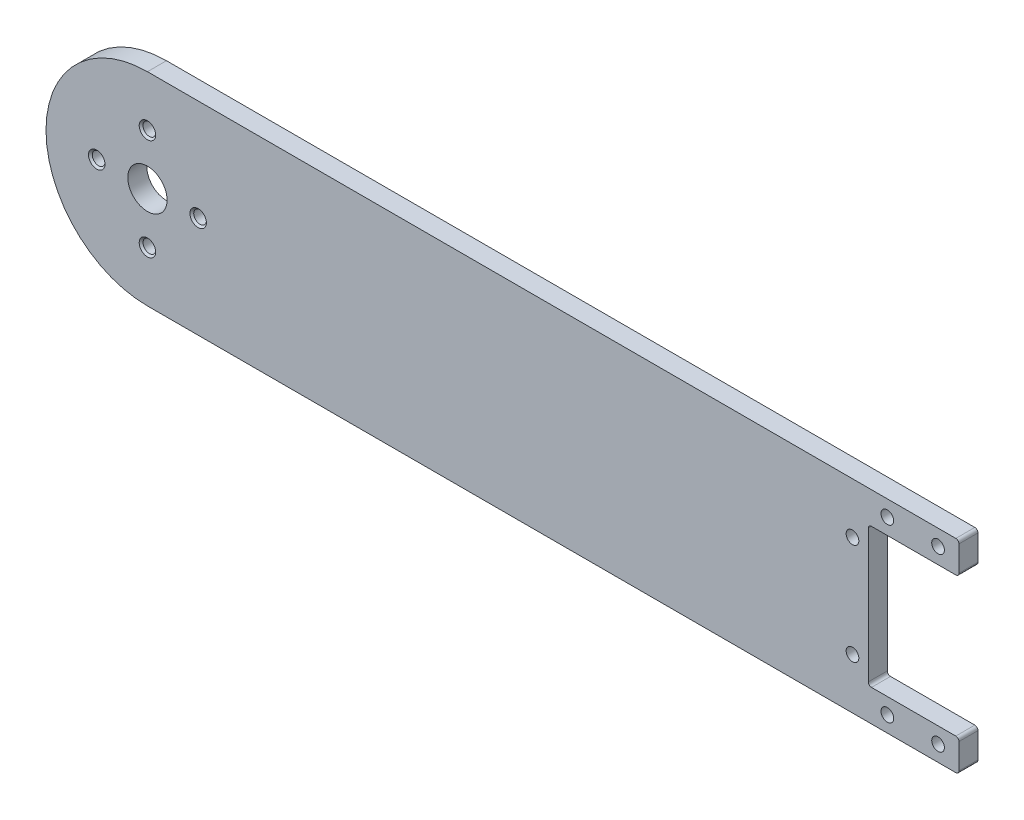
from build123d import *

# Parameters (mm, degrees)
Y_KSEKLIK_EKSTR_ZYON1_DEPTH                    = 3
IZIM2_R                                        = 3.1
KES_EKSTR_ZYON1_DEPTH                          = 4
M2_D_Z_BA_L_MAKINE_VIDAS_IN_HAV_A1_D           = 2
M2_D_Z_BA_L_MAKINE_VIDAS_IN_HAV_A1_CSINK_D     = 2.6
M2_D_Z_BA_L_MAKINE_VIDAS_IN_HAV_A1_CSINK_ANGLE = 90
IZIM26_W                                       = 22.3
IZIM26_H                                       = 22
KES_EKSTR_ZYON4_DEPTH                          = 4
M2_D_Z_BA_L_MAKINE_VIDAS_IN_HAV_A2_D           = 2
M2_D_Z_BA_L_MAKINE_VIDAS_IN_HAV_A2_CSINK_D     = 2.6
M2_D_Z_BA_L_MAKINE_VIDAS_IN_HAV_A2_CSINK_ANGLE = 90
IZIM33_W                                       = 8
IZIM33_H                                       = 32
KES_EKSTR_ZYON5_DEPTH                          = 10
RADYUS1_R                                      = 0.5


with BuildPart() as part:
    # Çizim1 → Yükseklik-Ekstrüzyon1 (new body)
    with BuildSketch(Plane.XY):
        with BuildLine():
            ThreePointArc((-61, 16), (-77, 0), (-61, -16))
            Line((-61, -16), (75, -16))
            Line((75, -16), (75, 16))
            Line((75, 16), (-61, 16))
        make_face()
    extrude(amount=Y_KSEKLIK_EKSTR_ZYON1_DEPTH)

    # Çizim2 → Kes-Ekstrüzyon1 (cut, through all)
    with BuildSketch(Plane.XY.offset(3)):
        with Locations((-61, 0)):
            Circle(IZIM2_R)
    extrude(amount=-KES_EKSTR_ZYON1_DEPTH, mode=Mode.SUBTRACT)

    # M2 Düz Başlı Makine Vidası İçin Havşa1 (through all)
    with Locations(Plane(origin=(-61, 8, 3), x_dir=(1, 0, 0), z_dir=(0, 0, 1))):
        with Locations((0, 0), (8, -8), (0, -16), (-8, -8)):
            CounterSinkHole(M2_D_Z_BA_L_MAKINE_VIDAS_IN_HAV_A1_D / 2, M2_D_Z_BA_L_MAKINE_VIDAS_IN_HAV_A1_CSINK_D / 2, counter_sink_angle=M2_D_Z_BA_L_MAKINE_VIDAS_IN_HAV_A1_CSINK_ANGLE)

    # Çizim26 → Kes-Ekstrüzyon4 (cut, through all)
    with BuildSketch(Plane.XY.offset(3)):
        with Locations((63.85, 0)):
            Rectangle(IZIM26_W, IZIM26_H)
    extrude(amount=-KES_EKSTR_ZYON4_DEPTH, mode=Mode.SUBTRACT)

    # M2 Düz Başlı Makine Vidası İçin Havşa2 (through all)
    with Locations(Plane(origin=(71.7, 13.5, 0), x_dir=(-1, 0, 0), z_dir=(0, 0, -1))):
        with Locations((0, 0), (8, 0), (16, 0), (21.5, -5.5), (21.5, -21.5), (16, -27), (8, -27), (0, -27)):
            CounterSinkHole(M2_D_Z_BA_L_MAKINE_VIDAS_IN_HAV_A2_D / 2, M2_D_Z_BA_L_MAKINE_VIDAS_IN_HAV_A2_CSINK_D / 2, counter_sink_angle=M2_D_Z_BA_L_MAKINE_VIDAS_IN_HAV_A2_CSINK_ANGLE)

    # Çizim33 → Kes-Ekstrüzyon5 (cut)
    with BuildSketch(Plane(origin=(0, 0, 0), x_dir=(-1, 0, 0), z_dir=(0, 0, -1))):
        with Locations((-71, 0)):
            Rectangle(IZIM33_W, IZIM33_H)
    extrude(amount=-KES_EKSTR_ZYON5_DEPTH, mode=Mode.SUBTRACT)

    # Radyus1
    radyus1_edges = [part.edges().sort_by_distance(p)[0] for p in [
        (67, 11, 1.5),
        (67, -11, 1.5),
        (67, 16, 1.5),
        (67, -16, 1.5),
        (52.7, -11, 1.5),
        (52.7, 11, 1.5),
    ]]
    fillet(radyus1_edges, radius=RADYUS1_R)


solid = part.part
